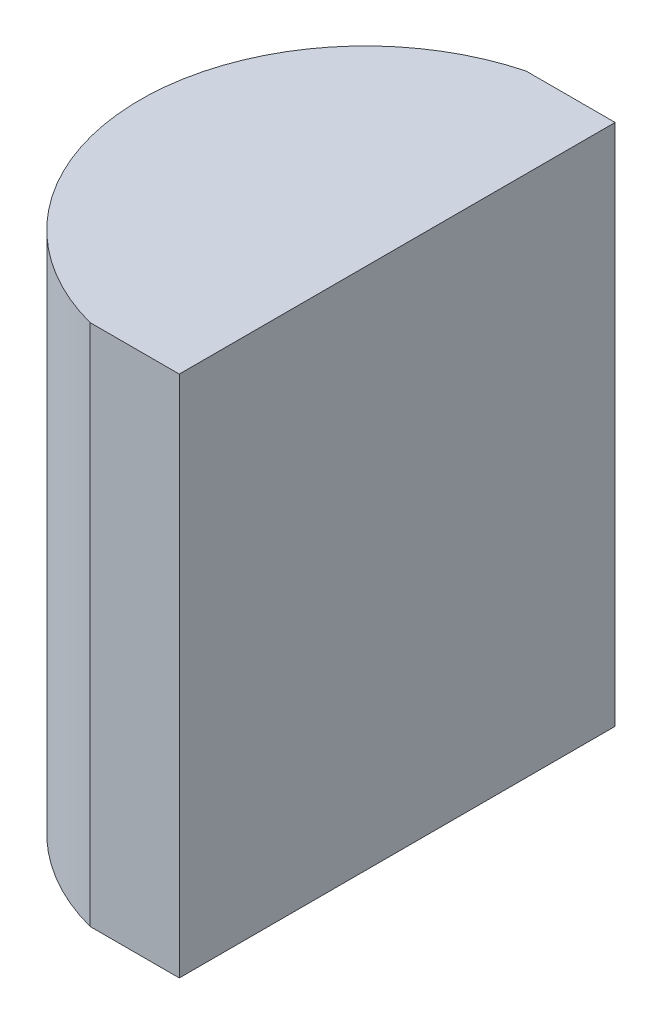
from build123d import *

# Parameters (mm, degrees)
EXTRUDE_1_DEPTH = 12


with BuildPart() as part:
    # 草图1 → 凸台-拉伸1 (new body)
    with BuildSketch(Plane(origin=(0, 0, 0), x_dir=(1, 0, 0), z_dir=(0, 1, 0))):
        with BuildLine():
            Line((3.040327915, 5), (5.085204335, 5))
            Line((5.085204335, 5), (5.085204335, -5))
            Line((5.085204335, -5), (3.040327915, -5))
            ThreePointArc((3.040327915, -5), (-0.814795665, 0), (3.040327915, 5))
        make_face()
    extrude(amount=EXTRUDE_1_DEPTH)


solid = part.part
